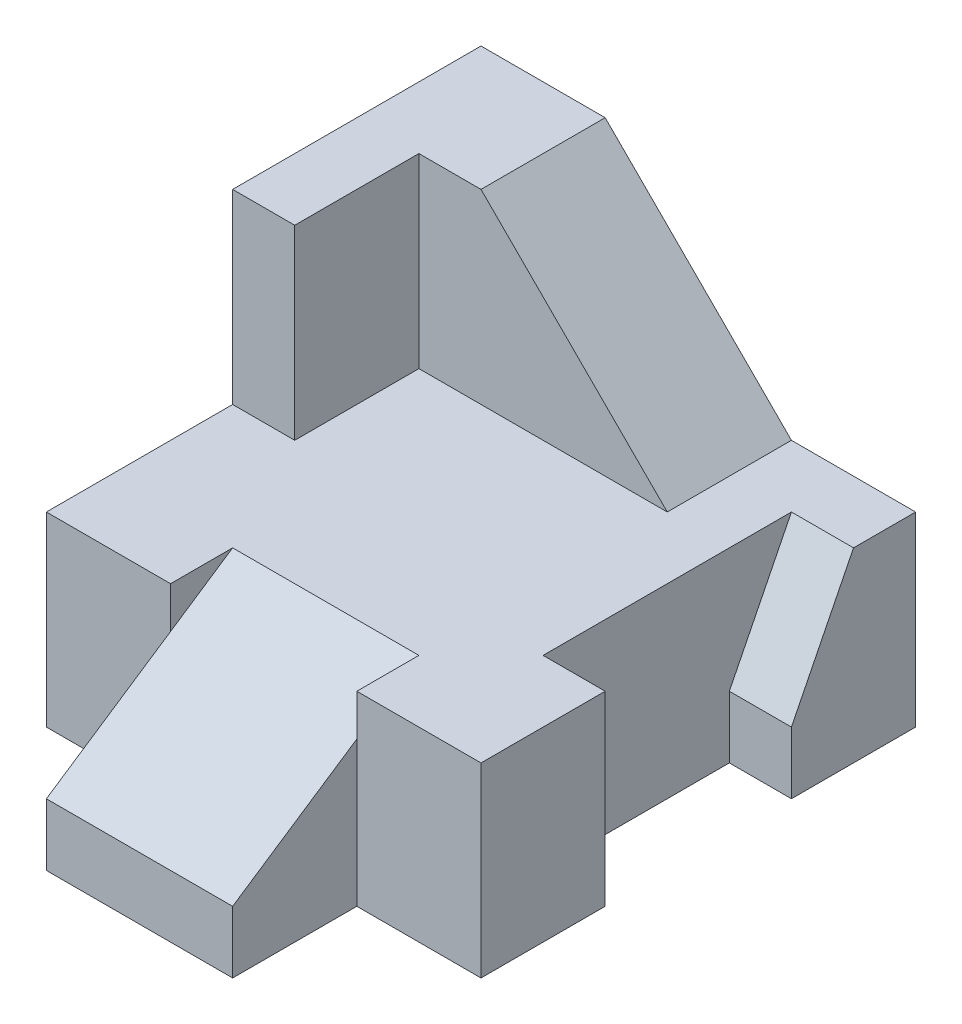
from build123d import *

# Parameters (mm, degrees)
SKETCH1_W           = 7
SKETCH1_H           = 6
BOSS_EXTRUDE1_DEPTH = 9
SKETCH2_W           = 2
SKETCH2_H           = 2
SKETCH2_W_2         = 1
SKETCH2_H_2         = 3
CUT_EXTRUDE1_DEPTH  = 7
SKETCH3_OUTSIDE_W   = 11.576
SKETCH3_OUTSIDE_H   = 13.576
CUT_EXTRUDE3_DEPTH  = 3
CUT_EXTRUDE4_DEPTH  = 3
CUT_EXTRUDE5_DEPTH  = 1
SKETCH8_W           = 3
SKETCH8_H           = 3.605551275
CUT_EXTRUDE6_DEPTH  = 5.160251472


with BuildPart() as part:
    # Sketch1 → Boss-Extrude1 (new body)
    with BuildSketch(Plane.XY):
        Rectangle(SKETCH1_W, SKETCH1_H)
    extrude(amount=BOSS_EXTRUDE1_DEPTH)

    # Sketch2 → Cut-Extrude1 (cut, through all)
    with BuildSketch(Plane(origin=(0, 3, 0), x_dir=(1, 0, 0), z_dir=(0, 1, 0))):
        with Locations((-2.5, -8)):
            Rectangle(SKETCH2_W, SKETCH2_H)
        with Locations((2.5, -8)):
            Rectangle(SKETCH2_W, SKETCH2_H)
        with Locations((3, -3.5)):
            Rectangle(SKETCH2_W_2, SKETCH2_H_2)
    extrude(amount=-CUT_EXTRUDE1_DEPTH, mode=Mode.SUBTRACT)

    # Sketch3 outside → Cut-Extrude3 (cut)
    with BuildSketch(Plane(origin=(0, 3, 0), x_dir=(1, 0, 0), z_dir=(0, 1, 0))):
        with Locations((0, -4.5)):
            Rectangle(SKETCH3_OUTSIDE_W, SKETCH3_OUTSIDE_H)
        Polygon((1.5, 0), (1.5, -2), (-2.5, -2), (-2.5, -4), (-3.5, -4), (-3.5, 0), align=None, mode=Mode.SUBTRACT)
    extrude(amount=-CUT_EXTRUDE3_DEPTH, mode=Mode.SUBTRACT)

    # Sketch4 → Cut-Extrude4 (cut)
    with BuildSketch(Plane.XY.offset(2)):
        Polygon((-1.5, 3), (1.5, 0), (1.5, 3), align=None)
    extrude(amount=-CUT_EXTRUDE4_DEPTH, mode=Mode.SUBTRACT)

    # Sketch5 → Cut-Extrude5 (cut)
    with BuildSketch(Plane(origin=(3.5, 0, 0), x_dir=(0, 0, -1), z_dir=(1, 0, 0))):
        Polygon((-1, 0), (-2, -2), (-2, 0), align=None)
    extrude(amount=-CUT_EXTRUDE5_DEPTH, mode=Mode.SUBTRACT)

    # Sketch8 → Cut-Extrude6 (cut, through all)
    with BuildSketch(Plane(origin=(0, 2.769230769, 1.846153846), x_dir=(1, 0, 0), z_dir=(0, 0.832050294, 0.554700196))):
        with Locations((0, -6.795077404)):
            Rectangle(SKETCH8_W, SKETCH8_H)
    extrude(amount=CUT_EXTRUDE6_DEPTH, mode=Mode.SUBTRACT)


solid = part.part
